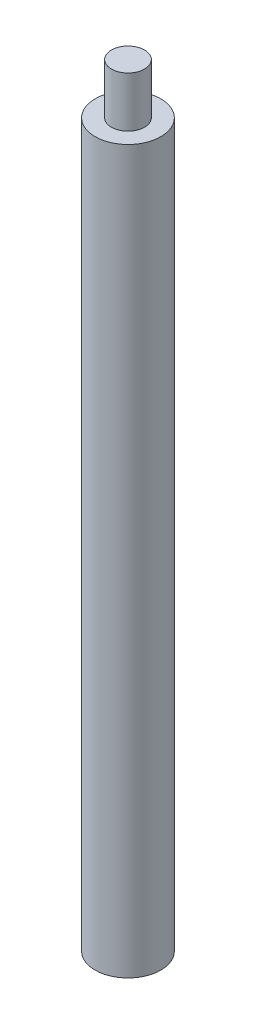
from build123d import *

# Parameters (mm, degrees)
SKETCH2_R                 = 1.984375
BOSS_EXTRUDE1_DEPTH       = 43.6372
SKETCH3_R                 = 1
BOSS_EXTRUDE2_DEPTH       = 3.048
M2X0_4_TAPPED_HOLE1_D     = 1.6
M2X0_4_TAPPED_HOLE1_DEPTH = 5.207
M2X0_4_TAPPED_HOLE1_TIP   = 0.480688495


with BuildPart() as part:
    # Sketch2 → Boss-Extrude1 (new body)
    with BuildSketch(Plane(origin=(0, 0, 0), x_dir=(1, 0, 0), z_dir=(0, 1, 0))):
        Circle(SKETCH2_R)
    extrude(amount=BOSS_EXTRUDE1_DEPTH)

    # Sketch3 → Boss-Extrude2 (add)
    with BuildSketch(Plane(origin=(0, 43.6372, 0), x_dir=(1, 0, 0), z_dir=(0, 1, 0))):
        Circle(SKETCH3_R)
    extrude(amount=BOSS_EXTRUDE2_DEPTH)

    # M2x0.4 Tapped Hole1
    with Locations(Plane(origin=(0, 0, 0), x_dir=(-1, 0, 0), z_dir=(0, -1, 0))):
        with Locations((0, 0)):
            Hole(M2X0_4_TAPPED_HOLE1_D / 2, depth=M2X0_4_TAPPED_HOLE1_DEPTH)
            with Locations((0, 0, -(M2X0_4_TAPPED_HOLE1_DEPTH + M2X0_4_TAPPED_HOLE1_TIP / 2))):  # 118° drill point
                Cone(0, M2X0_4_TAPPED_HOLE1_D / 2, M2X0_4_TAPPED_HOLE1_TIP, mode=Mode.SUBTRACT)


solid = part.part
